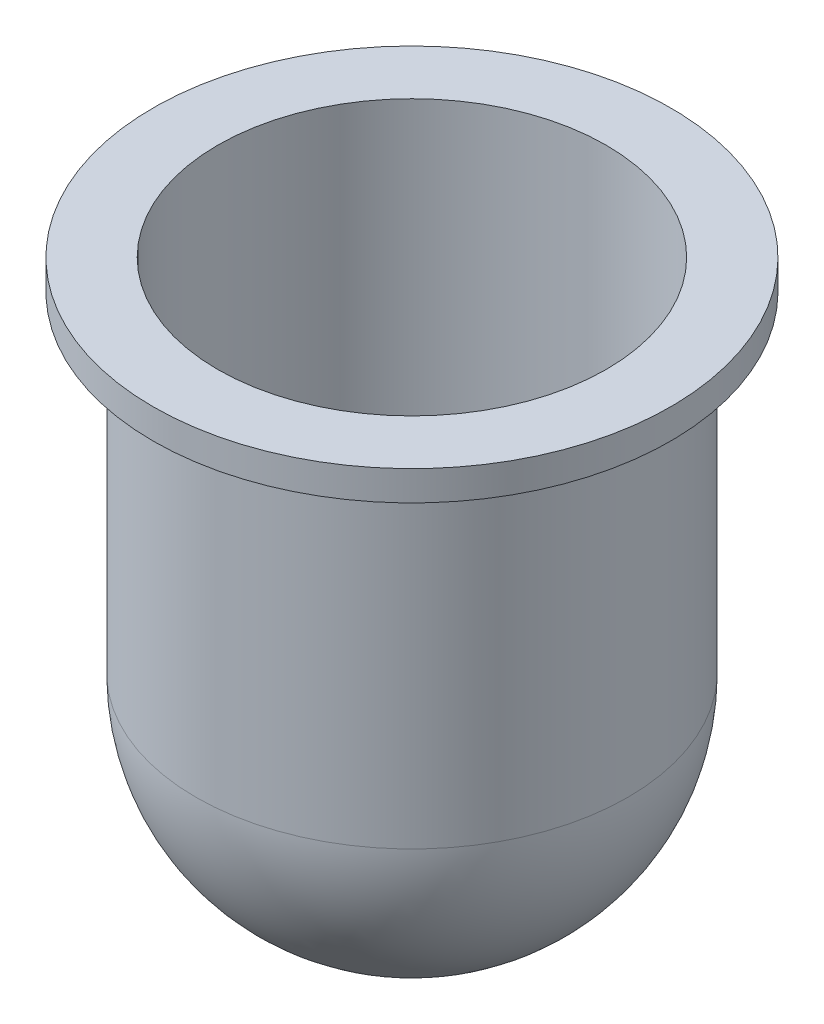
from build123d import *


with BuildPart() as part:
    # Sketch2 → Revolve1 (revolve)
    with BuildSketch(Plane.XY):
        with BuildLine():
            Line((-13.5, 40), (-13.5, 15))
            ThreePointArc((-13.5, 15), (-9.545941546, 5.454058454), (0, 1.5))
            Line((0, 1.5), (0, 0))
            ThreePointArc((0, 0), (-10.606601718, 4.393398282), (-15, 15))
            Line((-15, 15), (-15, 37.935568233))
            Line((-15, 37.935568233), (-17.985762804, 37.935568233))
            Line((-17.985762804, 37.935568233), (-17.985762804, 40))
            Line((-17.985762804, 40), (-15, 40))
            Line((-15, 40), (-13.5, 40))
        make_face()
    revolve(axis=Axis((0, 107.077522155, 0), (0, -1, 0)))


solid = part.part
